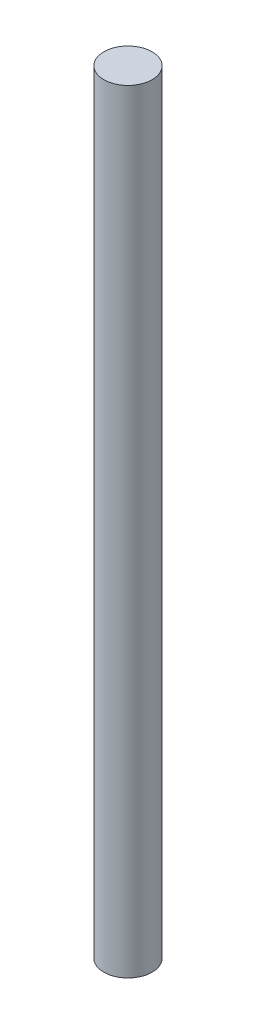
from build123d import *

# Parameters (mm, degrees)
SKETCH1_R           = 6.35
BOSS_EXTRUDE1_DEPTH = 101.6


with BuildPart() as part:
    # Sketch1 → Boss-Extrude1 (new body, symmetric)
    with BuildSketch(Plane(origin=(0, 0, 0), x_dir=(1, 0, 0), z_dir=(0, 1, 0))):
        Circle(SKETCH1_R)
    extrude(amount=BOSS_EXTRUDE1_DEPTH, both=True)


solid = part.part
